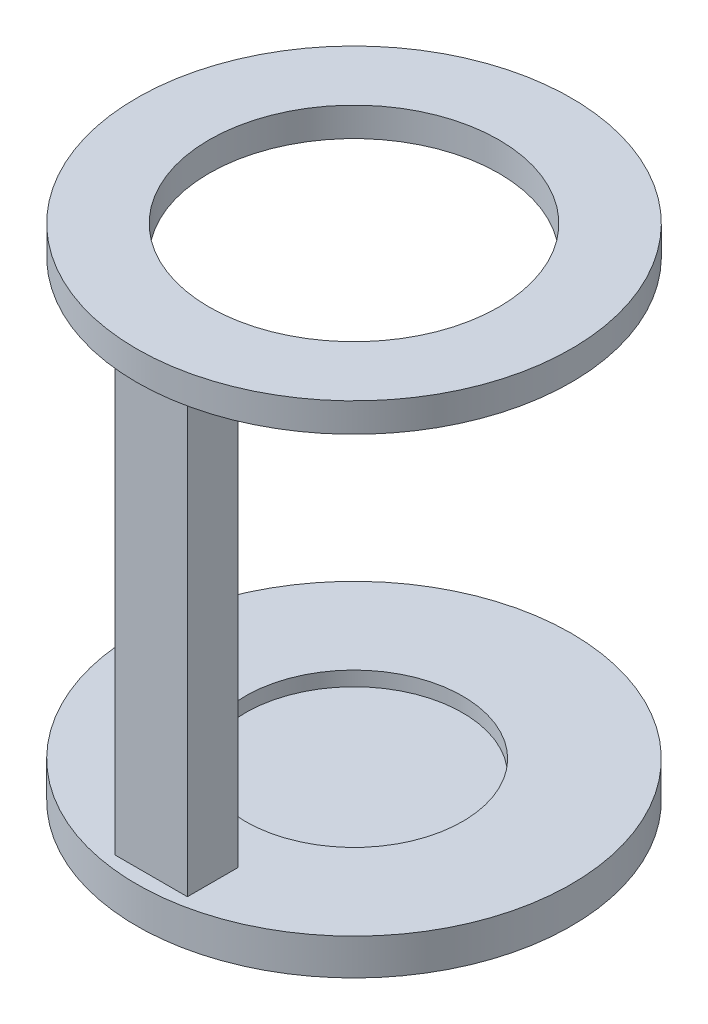
from build123d import *

# Parameters (mm, degrees)
SKETCH1_R           = 38.1
SKETCH1_R_2         = 25.4
BOSS_EXTRUDE1_DEPTH = 5.08
SKETCH4_W           = 12.7
SKETCH4_H           = 8.89
BOSS_EXTRUDE3_DEPTH = 76.2
SKETCH5_R           = 38.1
BOSS_EXTRUDE4_DEPTH = 6.35
SKETCH6_R           = 19.05
CUT_EXTRUDE1_DEPTH  = 2.54


with BuildPart() as part:
    # Sketch1 → Boss-Extrude1 (new body)
    with BuildSketch(Plane(origin=(0, 0, 0), x_dir=(1, 0, 0), z_dir=(0, 1, 0))):
        with Locations(Location((0, 0, 0), (0, 0, 270))):  # turned: the seam where the file's is
            Circle(SKETCH1_R)
        with Locations(Location((0, 0, 0), (0, 0, 270))):  # turned: the seam where the file's is
            Circle(SKETCH1_R_2, mode=Mode.SUBTRACT)
    extrude(amount=BOSS_EXTRUDE1_DEPTH)

    # Sketch4 → Boss-Extrude3 (add)
    with BuildSketch(Plane.XZ):
        with Locations((0, 31.115)):
            Rectangle(SKETCH4_W, SKETCH4_H)
    extrude(amount=BOSS_EXTRUDE3_DEPTH)

    # Sketch5 → Boss-Extrude4 (add)
    with BuildSketch(Plane.XZ.offset(76.2)):
        with Locations(Location((0, 0, 0), (0, 0, 90))):  # turned: the seam where the file's is
            Circle(SKETCH5_R)
    extrude(amount=BOSS_EXTRUDE4_DEPTH)

    # Sketch6 → Cut-Extrude1 (cut)
    with BuildSketch(Plane(origin=(0, -76.2, 0), x_dir=(1, 0, 0), z_dir=(0, 1, 0))):
        with Locations(Location((0, 0, 0), (0, 0, 270))):  # turned: the seam where the file's is
            Circle(SKETCH6_R)
    extrude(amount=-CUT_EXTRUDE1_DEPTH, mode=Mode.SUBTRACT)


solid = part.part
